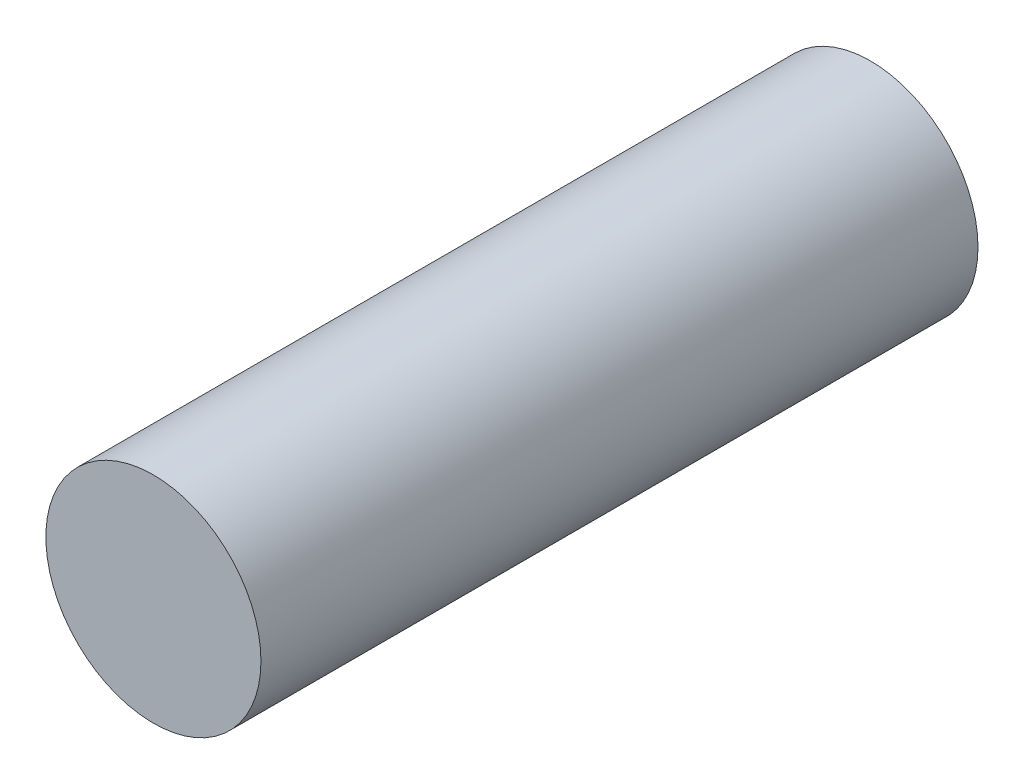
from build123d import *

# Parameters (mm, degrees)
SKETCH2_R           = 75
BOSS_EXTRUDE1_DEPTH = 500


with BuildPart() as part:
    # Sketch2 → Boss-Extrude1 (new body)
    with BuildSketch(Plane.XY.offset(650)):
        with Locations((129857.722301623, -224046.534343214)):
            Circle(SKETCH2_R)
    extrude(amount=-BOSS_EXTRUDE1_DEPTH)


solid = part.part
